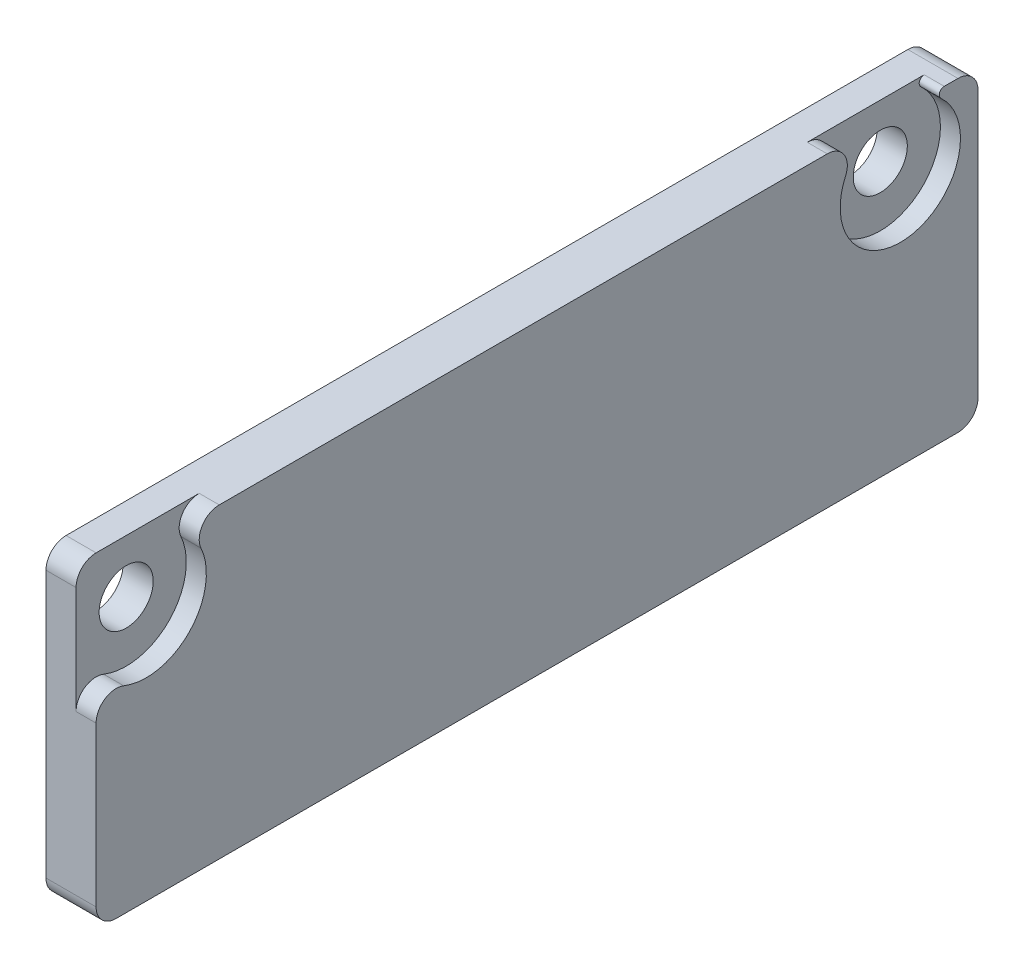
from build123d import *

# Parameters (mm, degrees)
SKETCH1_W                                          = 44
SKETCH1_H                                          = 15.3
BOSS_EXTRUDE1_DEPTH                                = 2.5
CBORE_FOR_M2_5_PAN_HEAD_MACHINE_SCREW1_D           = 2.7
CBORE_FOR_M2_5_PAN_HEAD_MACHINE_SCREW1_CBORE_D     = 6
CBORE_FOR_M2_5_PAN_HEAD_MACHINE_SCREW1_CBORE_DEPTH = 1
CUT_EXTRUDE1_DEPTH                                 = 1
FILLET1_R                                          = 1
FILLET2_R                                          = 0.25


with BuildPart() as part:
    # Sketch1 → Boss-Extrude1 (new body)
    with BuildSketch(Plane(origin=(0, 0, 0), x_dir=(0, 0, -1), z_dir=(1, 0, 0))):
        Rectangle(SKETCH1_W, SKETCH1_H)
    extrude(amount=BOSS_EXTRUDE1_DEPTH)

    # CBORE for M2.5 Pan Head Machine Screw1 (through all)
    with Locations(Plane(origin=(2.5, 0, 0), x_dir=(0, 0, -1), z_dir=(1, 0, 0))):
        with Locations((-19.5, 5), (18.125, 5)):
            CounterBoreHole(CBORE_FOR_M2_5_PAN_HEAD_MACHINE_SCREW1_D / 2, CBORE_FOR_M2_5_PAN_HEAD_MACHINE_SCREW1_CBORE_D / 2, CBORE_FOR_M2_5_PAN_HEAD_MACHINE_SCREW1_CBORE_DEPTH)

    # Sketch5 → Cut-Extrude1 (cut)
    with BuildSketch(Plane(origin=(2.5, 0, 0), x_dir=(0, 0, -1), z_dir=(1, 0, 0))):
        with BuildLine():
            ThreePointArc((-20.906236111, 7.65), (-21.515075982, 7.222491571), (-22, 6.658312395))
            Line((-22, 6.658312395), (-22, 7.65))
            Line((-22, 7.65), (-20.906236111, 7.65))
        make_face()
    extrude(amount=-CUT_EXTRUDE1_DEPTH, mode=Mode.SUBTRACT)

    # Fillet1
    fillet1_edges = [part.edges().sort_by_distance(p)[0] for p in [
        (2, 7.65, -16.718763889),
        (2, 7.65, 18.093763889),
        (2, 3.341687605, 22),
        (0.75, 7.65, 22),
        (1.25, -7.65, -22),
        (1.25, -7.65, 22),
        (1.25, 7.65, -22),
    ]]
    fillet(fillet1_edges, radius=FILLET1_R)

    # Fillet2
    fillet2_edges = [part.edges().sort_by_distance(p)[0] for p in [
        (2, 7.65, -19.531236111),
    ]]
    fillet(fillet2_edges, radius=FILLET2_R)


solid = part.part
